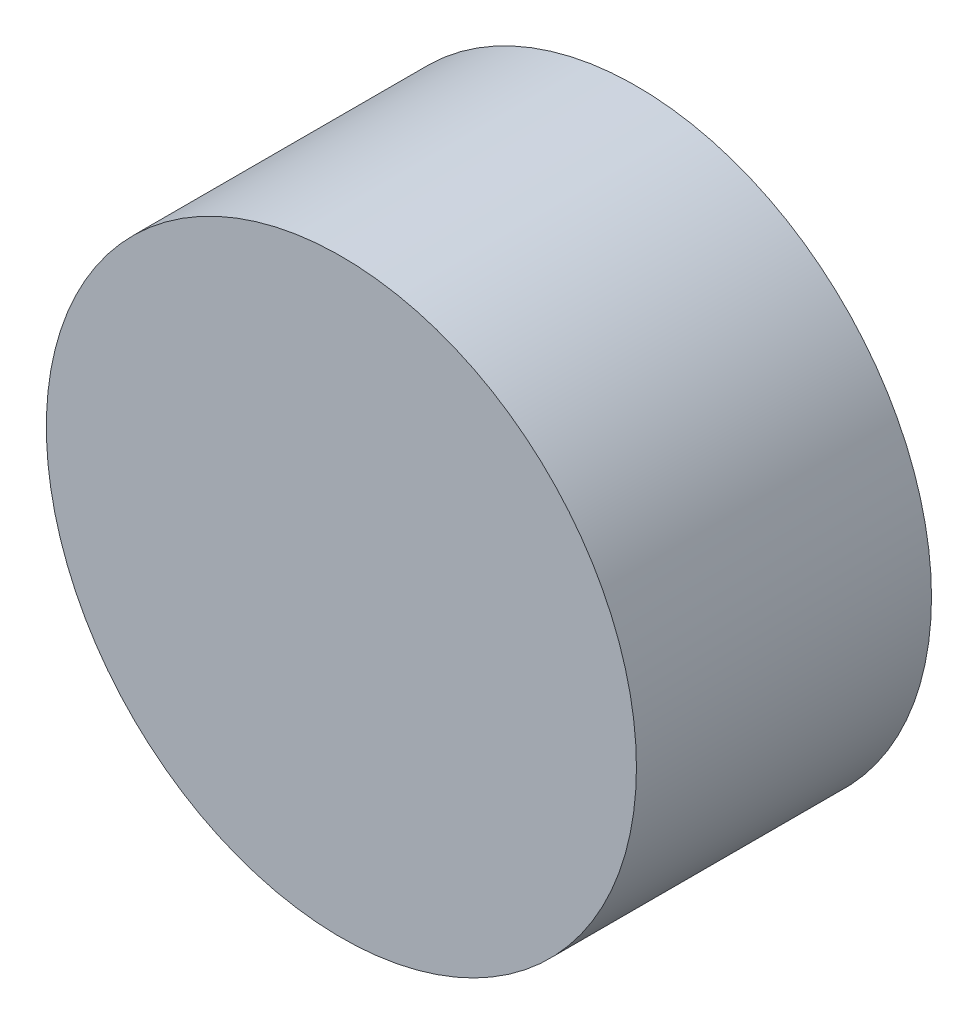
from build123d import *

# Parameters (mm, degrees)
SKETCH1_R           = 10
BOSS_EXTRUDE1_DEPTH = 10


with BuildPart() as part:
    # Sketch1 → Boss-Extrude1 (new body)
    with BuildSketch(Plane.XY):
        with Locations((-26.130877465, 18.771231597)):
            Circle(SKETCH1_R)
    extrude(amount=BOSS_EXTRUDE1_DEPTH)


solid = part.part
